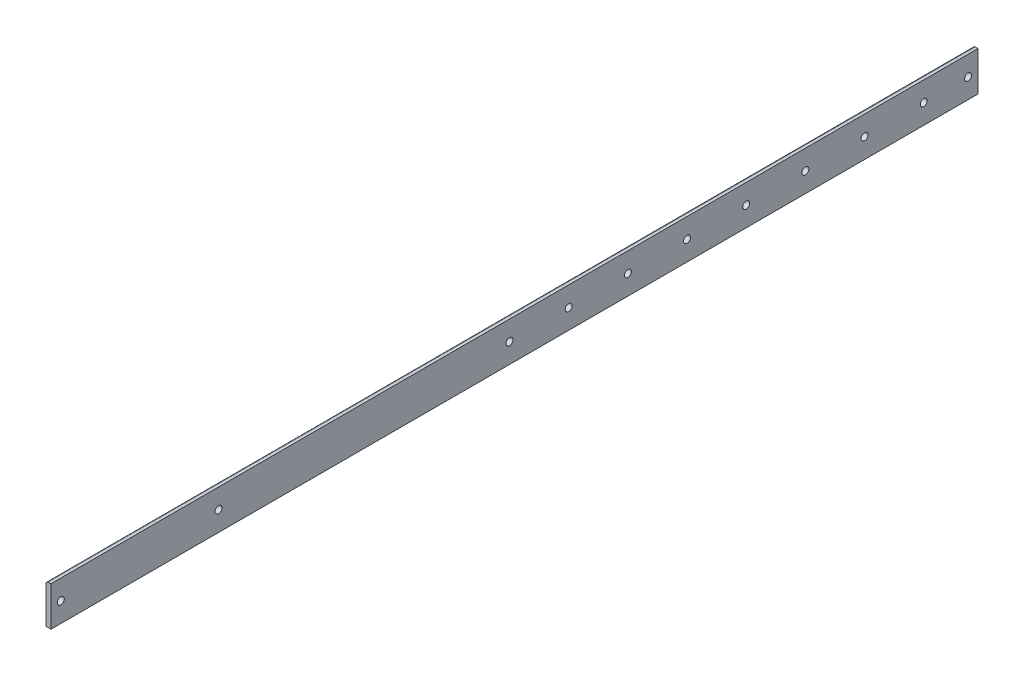
from build123d import *

# Parameters (mm, degrees)
BOSS_EXTRUDE1_DEPTH     = 304.8
SKETCH7_W               = 25.4
SKETCH7_H               = 12.7
CUT_EXTRUDE1_DEPTH      = 254
SKETCH3_R               = 2.5
CUT_EXTRUDE2_DEPTH      = 254
SKETCH8_R               = 2.25
CUT_EXTRUDE4_DEPTH      = 254
SKETCH9_W               = 22.225
SKETCH9_H               = 31.75
CUT_EXTRUDE5_DEPTH      = 12.7
CUT_EXTRUDE5_DEPTH_BACK = 12.7
SKETCH10_R              = 2.25
CUT_EXTRUDE6_DEPTH      = 203.2


with BuildPart() as part:
    # Sketch2 → Boss-Extrude1 (new, symmetric)
    with BuildSketch(Plane.XY):
        with BuildLine():
            Line((-12.7, -12.7), (12.7, -12.7))
            Line((12.7, -12.7), (12.7, 12.7))
            Line((12.7, 12.7), (11.1125, 12.7))
            ThreePointArc((11.1125, 12.7), (9.989967985, 12.235032015), (9.525, 11.1125))
            Line((9.525, 11.1125), (9.525, -6.35))
            ThreePointArc((9.525, -6.35), (8.59506403, -8.59506403), (6.35, -9.525))
            Line((6.35, -9.525), (-11.1125, -9.525))
            ThreePointArc((-11.1125, -9.525), (-12.235032015, -9.989967985), (-12.7, -11.1125))
            Line((-12.7, -11.1125), (-12.7, -12.7))
        make_face()
    extrude(amount=BOSS_EXTRUDE1_DEPTH, both=True)

    # Sketch7 → Cut-Extrude1 (cut)
    with BuildSketch(Plane.XZ.offset(12.7)):
        with Locations((0, 298.45)):
            Rectangle(SKETCH7_W, SKETCH7_H)
    extrude(amount=-CUT_EXTRUDE1_DEPTH, mode=Mode.SUBTRACT)

    # Sketch3 → Cut-Extrude2 (cut)
    with BuildSketch(Plane(origin=(0, 0, 0), x_dir=(1, 0, 0), z_dir=(0, 1, 0))):
        with Locations(Location((0, 273.05, 0), (0, 0, 270))):
            Circle(SKETCH3_R)
        with Locations(Location((0, 234.95, 0), (0, 0, 270))):
            Circle(SKETCH3_R)
        with Locations(Location((0, 196.85, 0), (0, 0, 270))):
            Circle(SKETCH3_R)
        with Locations(Location((0, 158.75, 0), (0, 0, 270))):
            Circle(SKETCH3_R)
        with Locations(Location((0, 120.65, 0), (0, 0, 270))):
            Circle(SKETCH3_R)
        with Locations(Location((0, 82.55, 0), (0, 0, 270))):
            Circle(SKETCH3_R)
        with Locations(Location((0, 44.45, 0), (0, 0, 270))):
            Circle(SKETCH3_R)
        with Locations(Location((0, 6.35, 0), (0, 0, 270))):
            Circle(SKETCH3_R)
        with Locations(Location((0, -31.75, 0), (0, 0, 270))):
            Circle(SKETCH3_R)
        with Locations(Location((0, -69.85, 0), (0, 0, 270))):
            Circle(SKETCH3_R)
        with Locations(Location((0, -107.95, 0), (0, 0, 270))):
            Circle(SKETCH3_R)
    extrude(amount=-CUT_EXTRUDE2_DEPTH, mode=Mode.SUBTRACT)

    # Sketch8 → Cut-Extrude4 (cut)
    with BuildSketch(Plane(origin=(12.7, 0, -12.7), x_dir=(0, 0, 1), z_dir=(-1, 0, 0))):
        with Locations(Location((9.525, 0, 0), (0, 0, 90))):
            Circle(SKETCH8_R)
        with Locations(Location((-28.575, 0, 0), (0, 0, 90))):
            Circle(SKETCH8_R)
        with Locations(Location((-66.675, 0, 0), (0, 0, 90))):
            Circle(SKETCH8_R)
        with Locations(Location((-104.775, 0, 0), (0, 0, 90))):
            Circle(SKETCH8_R)
        with Locations(Location((-142.875, 0, 0), (0, 0, 90))):
            Circle(SKETCH8_R)
        with Locations(Location((-180.975, 0, 0), (0, 0, 90))):
            Circle(SKETCH8_R)
        with Locations(Location((-219.075, 0, 0), (0, 0, 90))):
            Circle(SKETCH8_R)
        with Locations(Location((-285.75, 0, 0), (0, 0, 90))):
            Circle(SKETCH8_R)
        with Locations(Location((-257.175, 0, 0), (0, 0, 90))):
            Circle(SKETCH8_R)
        with Locations(Location((298.45, 0, 0), (0, 0, 90))):
            Circle(SKETCH8_R)
    extrude(amount=CUT_EXTRUDE4_DEPTH, mode=Mode.SUBTRACT)

    # Sketch9 → Cut-Extrude5 (cut, two sides)
    with BuildSketch(Plane(origin=(0, -9.525, 0), x_dir=(1, 0, 0), z_dir=(0, 1, 0))) as cut_extrude5_sk:
        with Locations((-1.5875, 288.925)):
            Rectangle(SKETCH9_W, SKETCH9_H)
        with Locations((-1.5875, -276.225)):
            Rectangle(SKETCH9_W, SKETCH9_H)
        with Locations((-1.5875, -34.925)):
            Rectangle(SKETCH9_W, SKETCH9_H)
        with Locations((-1.5875, -180.975)):
            Rectangle(SKETCH9_W, SKETCH9_H)
    extrude(amount=CUT_EXTRUDE5_DEPTH, mode=Mode.SUBTRACT)
    extrude(cut_extrude5_sk.sketch, amount=-CUT_EXTRUDE5_DEPTH_BACK, mode=Mode.SUBTRACT)

    # Sketch10 → Cut-Extrude6 (cut)
    with BuildSketch(Plane(origin=(12.7, 0, 0), x_dir=(0, 0, -1), z_dir=(1, 0, 0))):
        with Locations(Location((-184.15, 0, 0), (0, 0, 90))):
            Circle(SKETCH10_R)
        with Locations(Location((-285.75, 0, 0), (0, 0, 90))):
            Circle(SKETCH10_R)
    extrude(amount=-CUT_EXTRUDE6_DEPTH, mode=Mode.SUBTRACT)


solid = part.part
